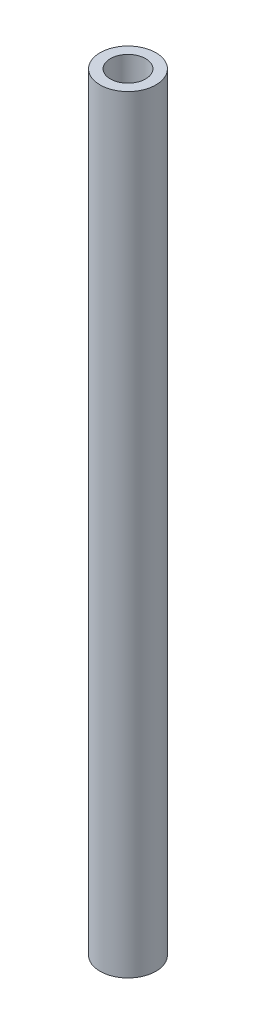
from build123d import *

# Parameters (mm, degrees)
SKETCH2_R                      = 4
BOSS_EXTRUDE1_DEPTH            = 110
F_8_0_199_DIAMETER_HOLE3_D     = 5.0546
F_8_0_199_DIAMETER_HOLE3_DEPTH = 10
F_8_0_199_DIAMETER_HOLE3_TIP   = 1.518555042
F_8_0_199_DIAMETER_HOLE4_D     = 5.0546
F_8_0_199_DIAMETER_HOLE4_DEPTH = 10
F_8_0_199_DIAMETER_HOLE4_TIP   = 1.518555042


with BuildPart() as part:
    # Sketch2 → Boss-Extrude1 (new body)
    with BuildSketch(Plane(origin=(0, 0, 0), x_dir=(1, 0, 0), z_dir=(0, 1, 0))):
        Circle(SKETCH2_R)
    extrude(amount=-BOSS_EXTRUDE1_DEPTH)

    # #8 (0.199) Diameter Hole3
    with Locations(Plane(origin=(0, 0, 0), x_dir=(1, 0, 0), z_dir=(0, 1, 0))):
        with Locations((0, 0)):
            Hole(F_8_0_199_DIAMETER_HOLE3_D / 2, depth=F_8_0_199_DIAMETER_HOLE3_DEPTH)
            with Locations((0, 0, -(F_8_0_199_DIAMETER_HOLE3_DEPTH + F_8_0_199_DIAMETER_HOLE3_TIP / 2))):  # 118° drill point
                Cone(0, F_8_0_199_DIAMETER_HOLE3_D / 2, F_8_0_199_DIAMETER_HOLE3_TIP, mode=Mode.SUBTRACT)

    # #8 (0.199) Diameter Hole4
    with Locations(Plane(origin=(0, -110, 0), x_dir=(-1, 0, 0), z_dir=(0, -1, 0))):
        with Locations((0, 0)):
            Hole(F_8_0_199_DIAMETER_HOLE4_D / 2, depth=F_8_0_199_DIAMETER_HOLE4_DEPTH)
            with Locations((0, 0, -(F_8_0_199_DIAMETER_HOLE4_DEPTH + F_8_0_199_DIAMETER_HOLE4_TIP / 2))):  # 118° drill point
                Cone(0, F_8_0_199_DIAMETER_HOLE4_D / 2, F_8_0_199_DIAMETER_HOLE4_TIP, mode=Mode.SUBTRACT)


solid = part.part
